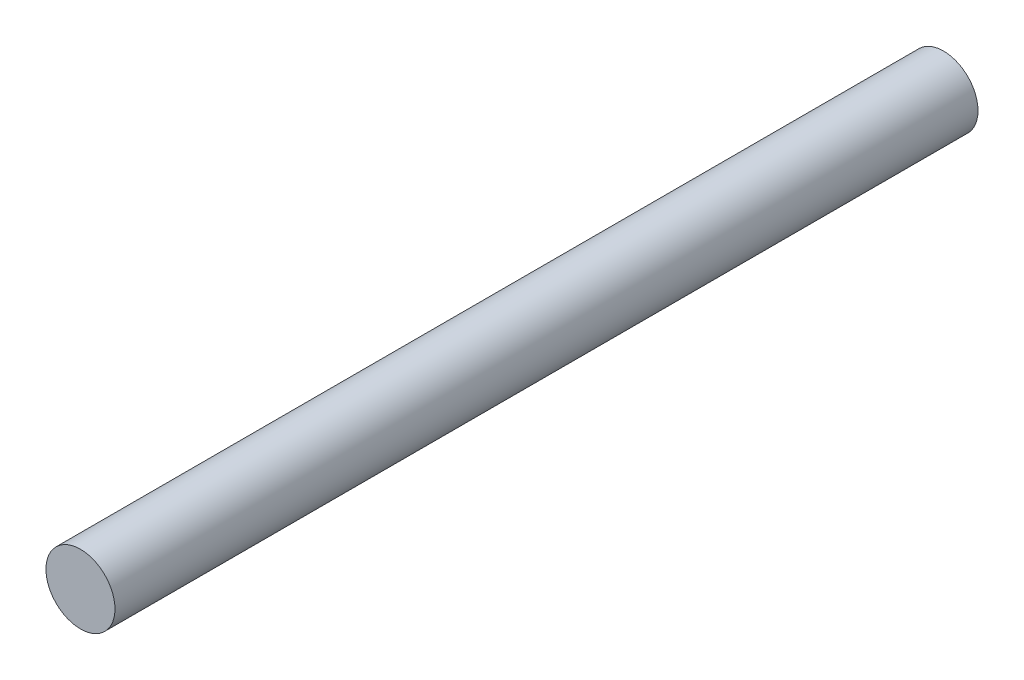
from build123d import *

# Parameters (mm, degrees)
SKETCH_1_R      = 4
EXTRUDE_1_DEPTH = 100


with BuildPart() as part:
    # 草图1 → 凸台-拉伸1 (new body)
    with BuildSketch(Plane.XY):
        Circle(SKETCH_1_R)
    extrude(amount=EXTRUDE_1_DEPTH)


solid = part.part
